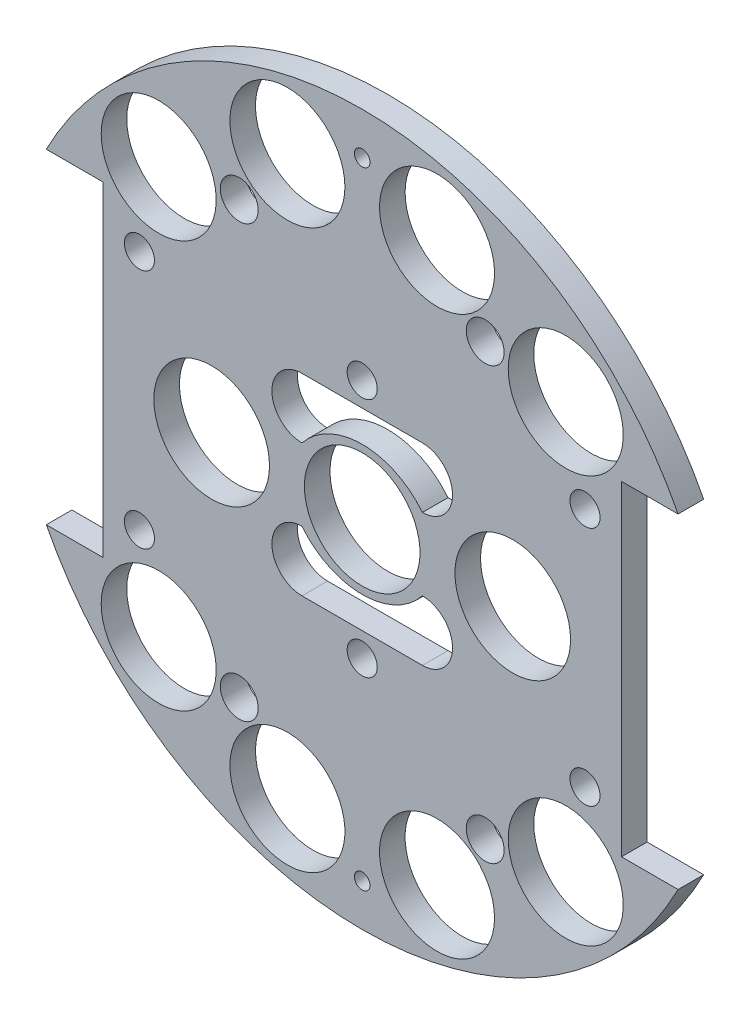
from build123d import *

# Parameters (mm, degrees)
SKETCH1_R                = 1.651
BOSS_EXTRUDE2_DEPTH      = 5.3975
SKETCH4_W                = 37.082318314
SKETCH4_H                = 34.047903563
SKETCH4_W_2              = 37.024578492
SKETCH4_H_2              = 32.488734362
BOSS_EXTRUDE3_DEPTH      = 5.3975
SKETCH3_R                = 12.192
SKETCH3_R_2              = 12.1285
CUT_EXTRUDE2_DEPTH       = 101.410849545
SKETCH12_R               = 4
CUT_EXTRUDE10_DEPTH      = 83.312
SKETCH15_R               = 1.651
CUT_EXTRUDE17_DEPTH      = 83.312
SKETCH35_R               = 3.175
CUT_EXTRUDE37_DEPTH      = 103.378
CUT_EXTRUDE37_DEPTH_BACK = 48.768
SKETCH40_R               = 12.192
CUT_EXTRUDE43_DEPTH      = 25.4


with BuildPart() as part:
    # Sketch1 → Boss-Extrude2 (new body)
    with BuildSketch(Plane.XY):
        with BuildLine():
            Line((-66.623575407, 34.29), (-54.685575407, 34.29))
            Line((-54.685575407, 34.29), (-54.685575407, -34.29))
            Line((-54.685575407, -34.29), (-66.623575407, -34.29))
            ThreePointArc((-66.623575407, -34.29), (0, -74.93), (66.623575407, -34.29))
            Line((66.623575407, -34.29), (54.685575407, -34.29))
            Line((54.685575407, -34.29), (54.685575407, 34.29))
            Line((54.685575407, 34.29), (66.623575407, 34.29))
            ThreePointArc((66.623575407, 34.29), (0, 74.93), (-66.623575407, 34.29))
        make_face()
        with Locations((-45.466, 11.049)):
            Circle(SKETCH1_R, mode=Mode.SUBTRACT)
        with Locations((-20.067270032, 10.795)):
            Circle(SKETCH1_R, mode=Mode.SUBTRACT)
        with Locations(Location((-20.067270032, -10.795, 0), (0, 0, 180))):
            Circle(SKETCH1_R, mode=Mode.SUBTRACT)
        with Locations(Location((-45.466, -11.049, 0), (0, 0, 180))):
            Circle(SKETCH1_R, mode=Mode.SUBTRACT)
        with Locations((45.466, -11.049)):
            Circle(SKETCH1_R, mode=Mode.SUBTRACT)
        with Locations((20.067270032, -10.795)):
            Circle(SKETCH1_R, mode=Mode.SUBTRACT)
        with Locations(Location((20.067270032, 10.795, 0), (0, 0, 180))):
            Circle(SKETCH1_R, mode=Mode.SUBTRACT)
        with Locations(Location((45.466, 11.049, 0), (0, 0, 180))):
            Circle(SKETCH1_R, mode=Mode.SUBTRACT)
    extrude(amount=BOSS_EXTRUDE2_DEPTH)

    # Sketch4 → Boss-Extrude3 (add)
    with BuildSketch(Plane(origin=(0, 0, 0), x_dir=(-1, 0, 0), z_dir=(0, 0, -1))):
        with Locations((32.991199211, -1.421154886)):
            Rectangle(SKETCH4_W, SKETCH4_H)
        with Locations((-34.085074962, -0.641570285)):
            Rectangle(SKETCH4_W_2, SKETCH4_H_2)
    extrude(amount=-BOSS_EXTRUDE3_DEPTH)

    # Sketch3 → Cut-Extrude2 (cut, through all)
    with BuildSketch(Plane(origin=(0, 0, 0), x_dir=(-1, 0, 0), z_dir=(0, 0, -1))):
        Circle(SKETCH3_R)
        with Locations((-42.926, -42.926)):
            Circle(SKETCH3_R_2)
        with Locations((15.777608989, -58.882838371)):
            Circle(SKETCH3_R_2)
        with Locations(Location((15.777608989, 58.882838371, 0), (0, 0, 180))):
            Circle(SKETCH3_R_2)
        with Locations((-42.926, 42.926)):
            Circle(SKETCH3_R_2)
        with Locations((42.926, 42.926)):
            Circle(SKETCH3_R_2)
        with Locations((-15.777608989, 58.882838371)):
            Circle(SKETCH3_R_2)
        with Locations(Location((-15.777608989, -58.882838371, 0), (0, 0, 180))):
            Circle(SKETCH3_R_2)
        with Locations((42.926, -42.926)):
            Circle(SKETCH3_R_2)
    extrude(amount=-CUT_EXTRUDE2_DEPTH, mode=Mode.SUBTRACT)

    # Sketch12 → Cut-Extrude10 (cut)
    with BuildSketch(Plane(origin=(0, 0, 0), x_dir=(-1, 0, 0), z_dir=(0, 0, -1))):
        with Locations((25.937608989, 45.466)):
            Circle(SKETCH12_R)
        with Locations((25.937608989, -45.466)):
            Circle(SKETCH12_R)
        with Locations(Location((-25.937608989, 45.466, 0), (0, 0, 180))):
            Circle(SKETCH12_R)
        with Locations(Location((-25.937608989, -45.466, 0), (0, 0, 180))):
            Circle(SKETCH12_R)
    extrude(amount=-CUT_EXTRUDE10_DEPTH, mode=Mode.SUBTRACT)

    # Sketch15 → Cut-Extrude17 (cut)
    with BuildSketch(Plane(origin=(0, 0, 0), x_dir=(-1, 0, 0), z_dir=(0, 0, -1))):
        with Locations((0, 66.04)):
            Circle(SKETCH15_R)
        with Locations(Location((0, -66.04, 0), (0, 0, 180))):
            Circle(SKETCH15_R)
    extrude(amount=-CUT_EXTRUDE17_DEPTH, mode=Mode.SUBTRACT)

    # Sketch35 → Cut-Extrude37 (cut, two sides)
    with BuildSketch(Plane(origin=(-30.092005081, 4.08352975, -42.4815), x_dir=(1, 0, 0), z_dir=(0, 0, 1))) as cut_extrude37_sk:
        with Locations((-16.897994919, 21.31647025)):
            Circle(SKETCH35_R)
        with Locations((77.082005081, 21.31647025)):
            Circle(SKETCH35_R)
        with Locations((30.092005081, 21.31647025)):
            Circle(SKETCH35_R)
        with Locations((77.082005081, -29.48352975)):
            Circle(SKETCH35_R)
        with Locations((30.092005081, -29.48352975)):
            Circle(SKETCH35_R)
        with Locations((-16.897994919, -29.48352975)):
            Circle(SKETCH35_R)
    extrude(amount=CUT_EXTRUDE37_DEPTH, mode=Mode.SUBTRACT)
    extrude(cut_extrude37_sk.sketch, amount=-CUT_EXTRUDE37_DEPTH_BACK, mode=Mode.SUBTRACT)

    # Sketch40 → Cut-Extrude43 (cut)
    with BuildSketch(Plane(origin=(0, 0, 0), x_dir=(-1, 0, 0), z_dir=(0, 0, -1))):
        with Locations((-31.75, 0)):
            Circle(SKETCH40_R)
        with Locations((31.75, 0)):
            Circle(SKETCH40_R)
        with BuildLine():
            Line((12.7, -20.32), (-12.7, -20.32))
            ThreePointArc((-12.7, -20.32), (-19.05, -13.97), (-12.7, -7.62))
            ThreePointArc((-12.7, -7.62), (0, -13.723935563), (12.7, -7.62))
            ThreePointArc((12.7, -7.62), (19.05, -13.97), (12.7, -20.32))
        make_face()
        with BuildLine():
            Line((12.7, 20.32), (-12.7, 20.32))
            ThreePointArc((-12.7, 20.32), (-19.05, 13.97), (-12.7, 7.62))
            ThreePointArc((-12.7, 7.62), (0, 13.723935563), (12.7, 7.62))
            ThreePointArc((12.7, 7.62), (19.05, 13.97), (12.7, 20.32))
        make_face()
    extrude(amount=-CUT_EXTRUDE43_DEPTH, mode=Mode.SUBTRACT)


solid = part.part
